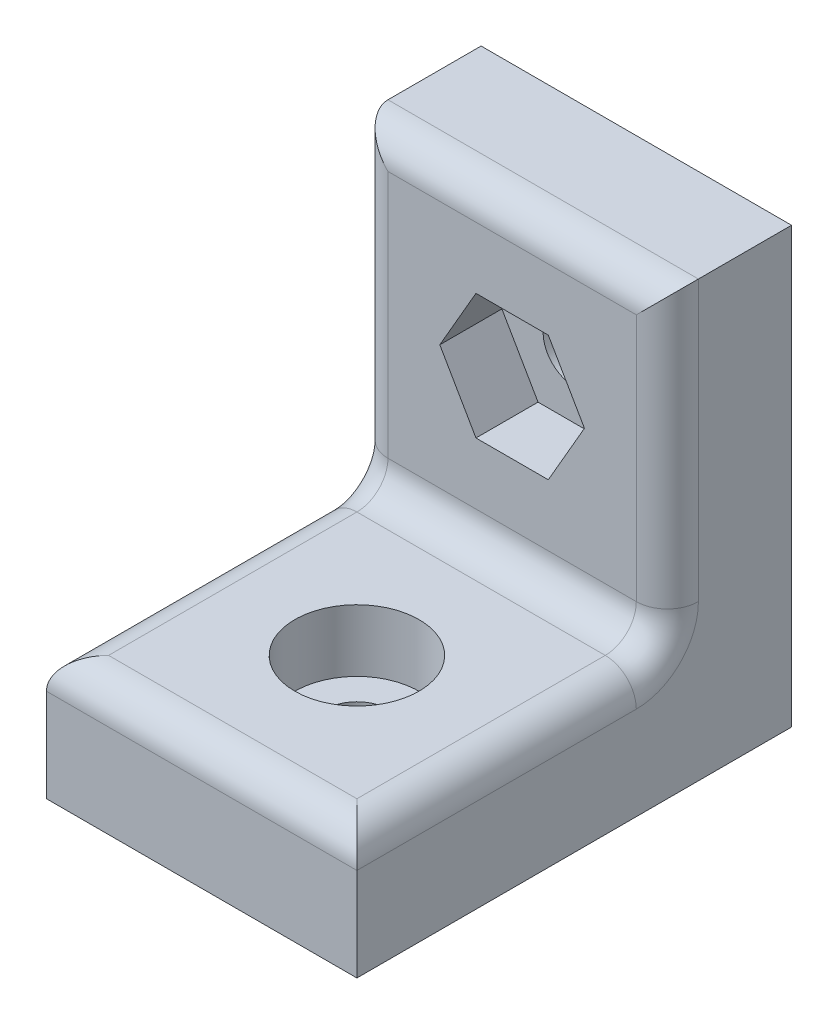
from build123d import *

# Parameters (mm, degrees)
ESQUISSE1_W             = 10
ESQUISSE1_H             = 14
BOSS_EXTRU_1_DEPTH      = 4
ESQUISSE2_W             = 10
ESQUISSE2_H             = 4
BOSS_EXTRU_2_DEPTH      = 10
ESQUISSE3_R             = 1
ENL_V_MAT_EXTRU_1_DEPTH = 5
CONG_1_R                = 1
ESQUISSE4_R             = 1
ENL_V_MAT_EXTRU_2_DEPTH = 5
ENL_V_MAT_EXTRU_3_DEPTH = 2
ESQUISSE6_R             = 2
ENL_V_MAT_EXTRU_4_DEPTH = 2


with BuildPart() as part:
    # Esquisse1 → Boss.-Extru.1 (new body)
    with BuildSketch(Plane.XY):
        with Locations((0, 7)):
            Rectangle(ESQUISSE1_W, ESQUISSE1_H)
    extrude(amount=BOSS_EXTRU_1_DEPTH)

    # Esquisse2 → Boss.-Extru.2 (add)
    with BuildSketch(Plane.XY.offset(4)):
        with Locations((0, 2)):
            Rectangle(ESQUISSE2_W, ESQUISSE2_H)
    extrude(amount=BOSS_EXTRU_2_DEPTH)

    # Esquisse3 → Enlèv. mat.-Extru.1 (cut, through all)
    with BuildSketch(Plane.XY.offset(4)):
        with Locations((0, 9)):
            Circle(ESQUISSE3_R)
    extrude(amount=-ENL_V_MAT_EXTRU_1_DEPTH, mode=Mode.SUBTRACT)

    # Congé1
    cong_1_edges = [part.edges().sort_by_distance(p)[0] for p in [
        (5, 9, 4),
        (-5, 4, 9),
        (0, 4, 4),
        (5, 4, 9),
        (0, 14, 4),
        (0, 4, 14),
        (-5, 9, 4),
    ]]
    fillet(cong_1_edges, radius=CONG_1_R)

    # Esquisse4 → Enlèv. mat.-Extru.2 (cut, through all)
    with BuildSketch(Plane(origin=(0, 4, 0), x_dir=(1, 0, 0), z_dir=(0, 1, 0))):
        with Locations(Location((0, -9, 0), (0, 0, 270))):  # turned: the seam where the file's is
            Circle(ESQUISSE4_R)
    extrude(amount=-ENL_V_MAT_EXTRU_2_DEPTH, mode=Mode.SUBTRACT)

    # Esquisse5 → Enlèv. mat.-Extru.3 (cut)
    with BuildSketch(Plane.XY.offset(4)):
        Polygon((1.165, 6.982160809), (2.33, 9), (1.165, 11.017839191), (-1.165, 11.017839191), (-2.33, 9), (-1.165, 6.982160809), align=None)
    extrude(amount=-ENL_V_MAT_EXTRU_3_DEPTH, mode=Mode.SUBTRACT)

    # Esquisse6 → Enlèv. mat.-Extru.4 (cut)
    with BuildSketch(Plane(origin=(0, 4, 0), x_dir=(1, 0, 0), z_dir=(0, 1, 0))):
        with Locations(Location((0, -9, 0), (0, 0, 270))):  # turned: the seam where the file's is
            Circle(ESQUISSE6_R)
    extrude(amount=-ENL_V_MAT_EXTRU_4_DEPTH, mode=Mode.SUBTRACT)


solid = part.part
